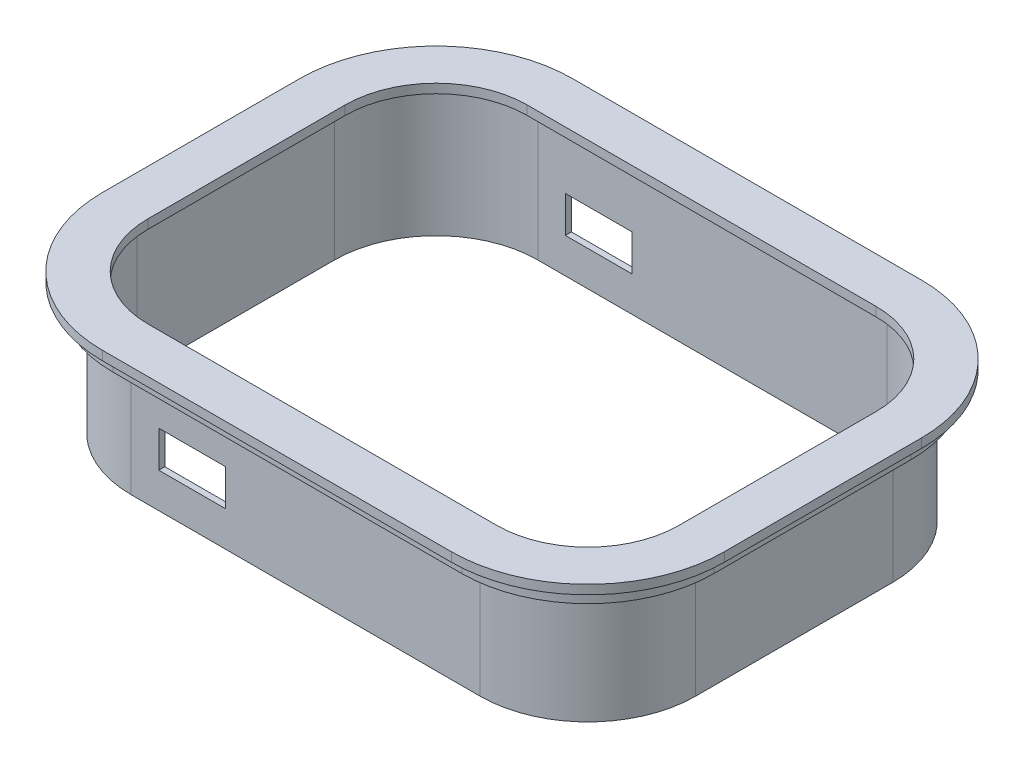
from build123d import *

# Parameters (mm, degrees)
BOSS_EXTRUDE1_DEPTH = 3
BOSS_EXTRUDE2_DEPTH = 5
BOSS_EXTRUDE3_DEPTH = 38
SKETCH4_W           = 22
SKETCH4_H           = 12
CUT_EXTRUDE1_DEPTH  = 461


with BuildPart() as part:
    # Sketch1 → Boss-Extrude1 (new body)
    with BuildSketch(Plane(origin=(0, 0, 0), x_dir=(1, 0, 0), z_dir=(0, 1, 0))):
        with BuildLine():
            Line((57.5, 77.5), (-57.5, 77.5))
            ThreePointArc((-57.5, 77.5), (-89.319805153, 64.319805153), (-102.5, 32.5))
            Line((-102.5, 32.5), (-102.5, -32.5))
            ThreePointArc((-102.5, -32.5), (-89.319805153, -64.319805153), (-57.5, -77.5))
            Line((-57.5, -77.5), (57.5, -77.5))
            ThreePointArc((57.5, -77.5), (89.319805153, -64.319805153), (102.5, -32.5))
            Line((102.5, -32.5), (102.5, 32.5))
            ThreePointArc((102.5, 32.5), (89.319805153, 64.319805153), (57.5, 77.5))
        make_face()
        with BuildLine():
            Line((57.5, -62.5), (-57.5, -62.5))
            ThreePointArc((-57.5, -62.5), (-78.713203436, -53.713203436), (-87.5, -32.5))
            Line((-87.5, -32.5), (-87.5, 32.5))
            ThreePointArc((-87.5, 32.5), (-78.713203436, 53.713203436), (-57.5, 62.5))
            Line((-57.5, 62.5), (57.5, 62.5))
            ThreePointArc((57.5, 62.5), (78.713203436, 53.713203436), (87.5, 32.5))
            Line((87.5, 32.5), (87.5, -32.5))
            ThreePointArc((87.5, -32.5), (78.713203436, -53.713203436), (57.5, -62.5))
        make_face(mode=Mode.SUBTRACT)
    extrude(amount=BOSS_EXTRUDE1_DEPTH)

    # Sketch1_4 → Boss-Extrude2 (add)
    # profile 1 of 2: a face of its own
    with BuildSketch(Plane(origin=(0, 0, 0), x_dir=(1, 0, 0), z_dir=(0, 1, 0))):
        with BuildLine():
            Line((57.5, 74), (-57.5, 74))
            ThreePointArc((-57.5, 74), (-86.844931419, 61.844931419), (-99, 32.5))
            Line((-99, 32.5), (-99, -32.5))
            ThreePointArc((-99, -32.5), (-86.844931419, -61.844931419), (-57.5, -74))
            Line((-57.5, -74), (57.5, -74))
            ThreePointArc((57.5, -74), (86.844931419, -61.844931419), (99, -32.5))
            Line((99, -32.5), (99, 32.5))
            ThreePointArc((99, 32.5), (86.844931419, 61.844931419), (57.5, 74))
        make_face()
        with BuildLine():
            ThreePointArc((-97, 32.5), (-85.430717857, 60.430717857), (-57.5, 72))
            Line((-57.5, 72), (57.5, 72))
            ThreePointArc((57.5, 72), (85.430717857, 60.430717857), (97, 32.5))
            Line((97, 32.5), (97, -32.5))
            ThreePointArc((97, -32.5), (85.430717857, -60.430717857), (57.5, -72))
            Line((57.5, -72), (-57.5, -72))
            ThreePointArc((-57.5, -72), (-85.430717857, -60.430717857), (-97, -32.5))
            Line((-97, -32.5), (-97, 32.5))
        make_face(mode=Mode.SUBTRACT)
    # profile 2 of 2: a face of its own
    with BuildSketch(Plane(origin=(0, 0, 0), x_dir=(1, 0, 0), z_dir=(0, 1, 0))):
        with BuildLine():
            Line((57.5, 68), (-57.5, 68))
            ThreePointArc((-57.5, 68), (-82.602290732, 57.602290732), (-93, 32.5))
            Line((-93, 32.5), (-93, -32.5))
            ThreePointArc((-93, -32.5), (-82.602290732, -57.602290732), (-57.5, -68))
            Line((-57.5, -68), (57.5, -68))
            ThreePointArc((57.5, -68), (82.602290732, -57.602290732), (93, -32.5))
            Line((93, -32.5), (93, 32.5))
            ThreePointArc((93, 32.5), (82.602290732, 57.602290732), (57.5, 68))
        make_face()
        with BuildLine():
            ThreePointArc((-91, 32.5), (-81.18807717, 56.18807717), (-57.5, 66))
            Line((-57.5, 66), (57.5, 66))
            ThreePointArc((57.5, 66), (81.18807717, 56.18807717), (91, 32.5))
            Line((91, 32.5), (91, -32.5))
            ThreePointArc((91, -32.5), (81.18807717, -56.18807717), (57.5, -66))
            Line((57.5, -66), (-57.5, -66))
            ThreePointArc((-57.5, -66), (-81.18807717, -56.18807717), (-91, -32.5))
            Line((-91, -32.5), (-91, 32.5))
        make_face(mode=Mode.SUBTRACT)
    extrude(amount=-BOSS_EXTRUDE2_DEPTH)

    # Sketch2 → Boss-Extrude3 (add)
    with BuildSketch(Plane.XZ.offset(5)):
        with BuildLine():
            Line((-57.5, -68), (57.5, -68))
            ThreePointArc((57.5, -68), (82.602290732, -57.602290732), (93, -32.5))
            Line((93, -32.5), (93, 32.5))
            ThreePointArc((93, 32.5), (82.602290732, 57.602290732), (57.5, 68))
            Line((57.5, 68), (-57.5, 68))
            ThreePointArc((-57.5, 68), (-82.602290732, 57.602290732), (-93, 32.5))
            Line((-93, 32.5), (-93, -32.5))
            ThreePointArc((-93, -32.5), (-82.602290732, -57.602290732), (-57.5, -68))
        make_face()
        with BuildLine():
            Line((-91, 32.5), (-91, -32.5))
            ThreePointArc((-91, -32.5), (-81.18807717, -56.18807717), (-57.5, -66))
            Line((-57.5, -66), (57.5, -66))
            ThreePointArc((57.5, -66), (81.18807717, -56.18807717), (91, -32.5))
            Line((91, -32.5), (91, 32.5))
            ThreePointArc((91, 32.5), (81.18807717, 56.18807717), (57.5, 66))
            Line((57.5, 66), (-57.5, 66))
            ThreePointArc((-57.5, 66), (-81.18807717, 56.18807717), (-91, 32.5))
        make_face(mode=Mode.SUBTRACT)
    extrude(amount=BOSS_EXTRUDE3_DEPTH)

    # Sketch4 → Cut-Extrude1 (cut)
    with BuildSketch(Plane.XY.offset(68)):
        with Locations((-37.400499866, -25.448136165)):
            Rectangle(SKETCH4_W, SKETCH4_H)
    extrude(amount=-CUT_EXTRUDE1_DEPTH, mode=Mode.SUBTRACT)


solid = part.part
